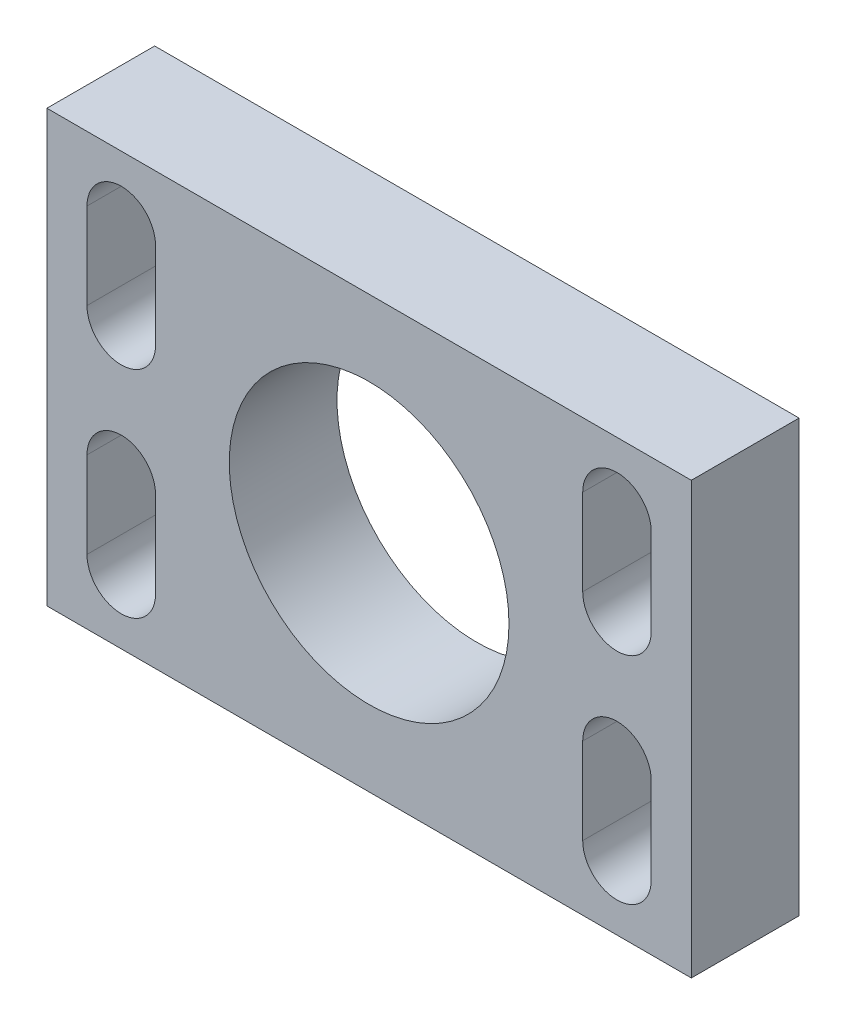
from build123d import *

# Parameters (mm, degrees)
SKETCH1_W                    = 29.9
SKETCH1_H                    = 5
BOSS_EXTRUDE1_DEPTH          = 20
SM05_THREADED_HOLE_REACH     = 33.395
F_4_40_CLEARANCE_SLOTS_REACH = 33.395


with BuildPart() as part:
    # Sketch1 → Boss-Extrude1 (new body)
    with BuildSketch(Plane(origin=(0, 0, 0), x_dir=(1, 0, 0), z_dir=(0, 1, 0))):
        with Locations((8.728625954, 0.935114504)):
            Rectangle(SKETCH1_W, SKETCH1_H)
    extrude(amount=BOSS_EXTRUDE1_DEPTH)

    # Sketch2 → SM05 threaded hole (cut, up to next)
    with BuildSketch(Plane.XY.offset(1.564885496), mode=Mode.PRIVATE) as sm05_threaded_hole_sk1:
        with BuildLine():
            ThreePointArc((15.218325954, 10), (13.317536832, 14.588910878), (8.728625954, 16.4897))
            Line((8.728625954, 16.4897), (8.728625954, 10))
            Line((8.728625954, 10), (15.218325954, 10))
        make_face()
    sm05_threaded_hole_tool1 = extrude(sm05_threaded_hole_sk1.sketch, amount=-SM05_THREADED_HOLE_REACH, mode=Mode.PRIVATE) & part.part
    # Sketch2 → SM05 threaded hole (cut, up to next)
    with BuildSketch(Plane.XY.offset(1.564885496), mode=Mode.PRIVATE) as sm05_threaded_hole_sk2:
        with BuildLine():
            Line((8.728625954, 10), (8.728625954, 16.4897))
            ThreePointArc((8.728625954, 16.4897), (4.139715076, 14.588910878), (2.238925954, 10))
            Line((2.238925954, 10), (8.728625954, 10))
        make_face()
    sm05_threaded_hole_tool2 = extrude(sm05_threaded_hole_sk2.sketch, amount=-SM05_THREADED_HOLE_REACH, mode=Mode.PRIVATE) & part.part
    # Sketch2 → SM05 threaded hole (cut, up to next)
    with BuildSketch(Plane.XY.offset(1.564885496), mode=Mode.PRIVATE) as sm05_threaded_hole_sk3:
        with BuildLine():
            Line((15.218325954, 10), (8.728625954, 10))
            Line((8.728625954, 10), (8.728625954, 3.5103))
            ThreePointArc((8.728625954, 3.5103), (13.317536832, 5.411089122), (15.218325954, 10))
        make_face()
    sm05_threaded_hole_tool3 = extrude(sm05_threaded_hole_sk3.sketch, amount=-SM05_THREADED_HOLE_REACH, mode=Mode.PRIVATE) & part.part
    # Sketch2 → SM05 threaded hole (cut, up to next)
    with BuildSketch(Plane.XY.offset(1.564885496), mode=Mode.PRIVATE) as sm05_threaded_hole_sk4:
        with BuildLine():
            Line((8.728625954, 3.5103), (8.728625954, 10))
            Line((8.728625954, 10), (2.238925954, 10))
            ThreePointArc((2.238925954, 10), (4.139715076, 5.411089122), (8.728625954, 3.5103))
        make_face()
    sm05_threaded_hole_tool4 = extrude(sm05_threaded_hole_sk4.sketch, amount=-SM05_THREADED_HOLE_REACH, mode=Mode.PRIVATE) & part.part
    # Sketch2 → SM05 threaded hole (cut, up to next)
    with BuildSketch(Plane.XY.offset(1.564885496), mode=Mode.PRIVATE) as sm05_threaded_hole_sk5:
        with BuildLine():
            ThreePointArc((15.218325954, 10), (13.317536832, 14.588910878), (8.728625954, 16.4897))
            Line((8.728625954, 16.4897), (8.728625954, 10))
            Line((8.728625954, 10), (15.218325954, 10))
        make_face()
    sm05_threaded_hole_tool5 = extrude(sm05_threaded_hole_sk5.sketch, amount=-SM05_THREADED_HOLE_REACH, mode=Mode.PRIVATE) & part.part
    # Sketch2 → SM05 threaded hole (cut, up to next)
    with BuildSketch(Plane.XY.offset(1.564885496), mode=Mode.PRIVATE) as sm05_threaded_hole_sk6:
        with BuildLine():
            Line((8.728625954, 10), (8.728625954, 16.4897))
            ThreePointArc((8.728625954, 16.4897), (4.139715076, 14.588910878), (2.238925954, 10))
            Line((2.238925954, 10), (8.728625954, 10))
        make_face()
    sm05_threaded_hole_tool6 = extrude(sm05_threaded_hole_sk6.sketch, amount=-SM05_THREADED_HOLE_REACH, mode=Mode.PRIVATE) & part.part
    # Sketch2 → SM05 threaded hole (cut, up to next)
    with BuildSketch(Plane.XY.offset(1.564885496), mode=Mode.PRIVATE) as sm05_threaded_hole_sk7:
        with BuildLine():
            Line((15.218325954, 10), (8.728625954, 10))
            Line((8.728625954, 10), (8.728625954, 3.5103))
            ThreePointArc((8.728625954, 3.5103), (13.317536832, 5.411089122), (15.218325954, 10))
        make_face()
    sm05_threaded_hole_tool7 = extrude(sm05_threaded_hole_sk7.sketch, amount=-SM05_THREADED_HOLE_REACH, mode=Mode.PRIVATE) & part.part
    # Sketch2 → SM05 threaded hole (cut, up to next)
    with BuildSketch(Plane.XY.offset(1.564885496), mode=Mode.PRIVATE) as sm05_threaded_hole_sk8:
        with BuildLine():
            Line((8.728625954, 3.5103), (8.728625954, 10))
            Line((8.728625954, 10), (2.238925954, 10))
            ThreePointArc((2.238925954, 10), (4.139715076, 5.411089122), (8.728625954, 3.5103))
        make_face()
    sm05_threaded_hole_tool8 = extrude(sm05_threaded_hole_sk8.sketch, amount=-SM05_THREADED_HOLE_REACH, mode=Mode.PRIVATE) & part.part
    # Sketch2 → SM05 threaded hole (cut, up to next)
    with BuildSketch(Plane.XY.offset(1.564885496), mode=Mode.PRIVATE) as sm05_threaded_hole_sk9:
        with BuildLine():
            ThreePointArc((15.218325954, 10), (13.317536832, 14.588910878), (8.728625954, 16.4897))
            Line((8.728625954, 16.4897), (8.728625954, 10))
            Line((8.728625954, 10), (15.218325954, 10))
        make_face()
    sm05_threaded_hole_tool9 = extrude(sm05_threaded_hole_sk9.sketch, amount=-SM05_THREADED_HOLE_REACH, mode=Mode.PRIVATE) & part.part
    # Sketch2 → SM05 threaded hole (cut, up to next)
    with BuildSketch(Plane.XY.offset(1.564885496), mode=Mode.PRIVATE) as sm05_threaded_hole_sk10:
        with BuildLine():
            Line((8.728625954, 10), (8.728625954, 16.4897))
            ThreePointArc((8.728625954, 16.4897), (4.139715076, 14.588910878), (2.238925954, 10))
            Line((2.238925954, 10), (8.728625954, 10))
        make_face()
    sm05_threaded_hole_tool10 = extrude(sm05_threaded_hole_sk10.sketch, amount=-SM05_THREADED_HOLE_REACH, mode=Mode.PRIVATE) & part.part
    # Sketch2 → SM05 threaded hole (cut, up to next)
    with BuildSketch(Plane.XY.offset(1.564885496), mode=Mode.PRIVATE) as sm05_threaded_hole_sk11:
        with BuildLine():
            Line((15.218325954, 10), (8.728625954, 10))
            Line((8.728625954, 10), (8.728625954, 3.5103))
            ThreePointArc((8.728625954, 3.5103), (13.317536832, 5.411089122), (15.218325954, 10))
        make_face()
    sm05_threaded_hole_tool11 = extrude(sm05_threaded_hole_sk11.sketch, amount=-SM05_THREADED_HOLE_REACH, mode=Mode.PRIVATE) & part.part
    # Sketch2 → SM05 threaded hole (cut, up to next)
    with BuildSketch(Plane.XY.offset(1.564885496), mode=Mode.PRIVATE) as sm05_threaded_hole_sk12:
        with BuildLine():
            Line((8.728625954, 3.5103), (8.728625954, 10))
            Line((8.728625954, 10), (2.238925954, 10))
            ThreePointArc((2.238925954, 10), (4.139715076, 5.411089122), (8.728625954, 3.5103))
        make_face()
    sm05_threaded_hole_tool12 = extrude(sm05_threaded_hole_sk12.sketch, amount=-SM05_THREADED_HOLE_REACH, mode=Mode.PRIVATE) & part.part
    # Sketch2 → SM05 threaded hole (cut, up to next)
    with BuildSketch(Plane.XY.offset(1.564885496), mode=Mode.PRIVATE) as sm05_threaded_hole_sk13:
        with BuildLine():
            ThreePointArc((15.218325954, 10), (13.317536832, 14.588910878), (8.728625954, 16.4897))
            Line((8.728625954, 16.4897), (8.728625954, 10))
            Line((8.728625954, 10), (15.218325954, 10))
        make_face()
    sm05_threaded_hole_tool13 = extrude(sm05_threaded_hole_sk13.sketch, amount=-SM05_THREADED_HOLE_REACH, mode=Mode.PRIVATE) & part.part
    # Sketch2 → SM05 threaded hole (cut, up to next)
    with BuildSketch(Plane.XY.offset(1.564885496), mode=Mode.PRIVATE) as sm05_threaded_hole_sk14:
        with BuildLine():
            Line((8.728625954, 10), (8.728625954, 16.4897))
            ThreePointArc((8.728625954, 16.4897), (4.139715076, 14.588910878), (2.238925954, 10))
            Line((2.238925954, 10), (8.728625954, 10))
        make_face()
    sm05_threaded_hole_tool14 = extrude(sm05_threaded_hole_sk14.sketch, amount=-SM05_THREADED_HOLE_REACH, mode=Mode.PRIVATE) & part.part
    # Sketch2 → SM05 threaded hole (cut, up to next)
    with BuildSketch(Plane.XY.offset(1.564885496), mode=Mode.PRIVATE) as sm05_threaded_hole_sk15:
        with BuildLine():
            Line((15.218325954, 10), (8.728625954, 10))
            Line((8.728625954, 10), (8.728625954, 3.5103))
            ThreePointArc((8.728625954, 3.5103), (13.317536832, 5.411089122), (15.218325954, 10))
        make_face()
    sm05_threaded_hole_tool15 = extrude(sm05_threaded_hole_sk15.sketch, amount=-SM05_THREADED_HOLE_REACH, mode=Mode.PRIVATE) & part.part
    # Sketch2 → SM05 threaded hole (cut, up to next)
    with BuildSketch(Plane.XY.offset(1.564885496), mode=Mode.PRIVATE) as sm05_threaded_hole_sk16:
        with BuildLine():
            Line((8.728625954, 3.5103), (8.728625954, 10))
            Line((8.728625954, 10), (2.238925954, 10))
            ThreePointArc((2.238925954, 10), (4.139715076, 5.411089122), (8.728625954, 3.5103))
        make_face()
    sm05_threaded_hole_tool16 = extrude(sm05_threaded_hole_sk16.sketch, amount=-SM05_THREADED_HOLE_REACH, mode=Mode.PRIVATE) & part.part
    add(sm05_threaded_hole_tool1.solids().sort_by_distance((11.48294, 12.754314, 1.564885))[0], mode=Mode.SUBTRACT)
    add(sm05_threaded_hole_tool2.solids().sort_by_distance((5.974312, 12.754314, 1.564885))[0], mode=Mode.SUBTRACT)
    add(sm05_threaded_hole_tool3.solids().sort_by_distance((11.48294, 7.245686, 1.564885))[0], mode=Mode.SUBTRACT)
    add(sm05_threaded_hole_tool4.solids().sort_by_distance((5.974312, 7.245686, 1.564885))[0], mode=Mode.SUBTRACT)
    add(sm05_threaded_hole_tool5.solids().sort_by_distance((11.48294, 12.754314, 1.564885))[0], mode=Mode.SUBTRACT)
    add(sm05_threaded_hole_tool6.solids().sort_by_distance((5.974312, 12.754314, 1.564885))[0], mode=Mode.SUBTRACT)
    add(sm05_threaded_hole_tool7.solids().sort_by_distance((11.48294, 7.245686, 1.564885))[0], mode=Mode.SUBTRACT)
    add(sm05_threaded_hole_tool8.solids().sort_by_distance((5.974312, 7.245686, 1.564885))[0], mode=Mode.SUBTRACT)
    add(sm05_threaded_hole_tool9.solids().sort_by_distance((11.48294, 12.754314, 1.564885))[0], mode=Mode.SUBTRACT)
    add(sm05_threaded_hole_tool10.solids().sort_by_distance((5.974312, 12.754314, 1.564885))[0], mode=Mode.SUBTRACT)
    add(sm05_threaded_hole_tool11.solids().sort_by_distance((11.48294, 7.245686, 1.564885))[0], mode=Mode.SUBTRACT)
    add(sm05_threaded_hole_tool12.solids().sort_by_distance((5.974312, 7.245686, 1.564885))[0], mode=Mode.SUBTRACT)
    add(sm05_threaded_hole_tool13.solids().sort_by_distance((11.48294, 12.754314, 1.564885))[0], mode=Mode.SUBTRACT)
    add(sm05_threaded_hole_tool14.solids().sort_by_distance((5.974312, 12.754314, 1.564885))[0], mode=Mode.SUBTRACT)
    add(sm05_threaded_hole_tool15.solids().sort_by_distance((11.48294, 7.245686, 1.564885))[0], mode=Mode.SUBTRACT)
    add(sm05_threaded_hole_tool16.solids().sort_by_distance((5.974312, 7.245686, 1.564885))[0], mode=Mode.SUBTRACT)

    # Sketch2_3 → 4-40 clearance slots (cut, up to next)
    with BuildSketch(Plane.XY.offset(1.564885496), mode=Mode.PRIVATE) as f_4_40_clearance_slots_sk1:
        with BuildLine():
            Line((-1.181374046, 13), (-1.181374046, 17))
            ThreePointArc((-1.181374046, 17), (-2.771374046, 18.59), (-4.361374046, 17))
            Line((-4.361374046, 17), (-4.361374046, 13))
            ThreePointArc((-4.361374046, 13), (-2.771374046, 11.41), (-1.181374046, 13))
        make_face()
    f_4_40_clearance_slots_tool1 = extrude(f_4_40_clearance_slots_sk1.sketch, amount=-F_4_40_CLEARANCE_SLOTS_REACH, mode=Mode.PRIVATE) & part.part
    # Sketch2_3 → 4-40 clearance slots (cut, up to next)
    with BuildSketch(Plane.XY.offset(1.564885496), mode=Mode.PRIVATE) as f_4_40_clearance_slots_sk2:
        with BuildLine():
            ThreePointArc((-1.181374046, 3), (-2.771374046, 1.41), (-4.361374046, 3))
            Line((-4.361374046, 3), (-4.361374046, 7))
            ThreePointArc((-4.361374046, 7), (-2.771374046, 8.59), (-1.181374046, 7))
            Line((-1.181374046, 7), (-1.181374046, 3))
        make_face()
    f_4_40_clearance_slots_tool2 = extrude(f_4_40_clearance_slots_sk2.sketch, amount=-F_4_40_CLEARANCE_SLOTS_REACH, mode=Mode.PRIVATE) & part.part
    # Sketch2_3 → 4-40 clearance slots (cut, up to next)
    with BuildSketch(Plane.XY.offset(1.564885496), mode=Mode.PRIVATE) as f_4_40_clearance_slots_sk3:
        with BuildLine():
            Line((18.638625954, 7), (18.638625954, 3))
            ThreePointArc((18.638625954, 3), (20.228625954, 1.41), (21.818625954, 3))
            Line((21.818625954, 3), (21.818625954, 7))
            ThreePointArc((21.818625954, 7), (20.228625954, 8.59), (18.638625954, 7))
        make_face()
    f_4_40_clearance_slots_tool3 = extrude(f_4_40_clearance_slots_sk3.sketch, amount=-F_4_40_CLEARANCE_SLOTS_REACH, mode=Mode.PRIVATE) & part.part
    # Sketch2_3 → 4-40 clearance slots (cut, up to next)
    with BuildSketch(Plane.XY.offset(1.564885496), mode=Mode.PRIVATE) as f_4_40_clearance_slots_sk4:
        with BuildLine():
            ThreePointArc((18.638625954, 17), (20.228625954, 18.59), (21.818625954, 17))
            Line((21.818625954, 17), (21.818625954, 13))
            ThreePointArc((21.818625954, 13), (20.228625954, 11.41), (18.638625954, 13))
            Line((18.638625954, 13), (18.638625954, 17))
        make_face()
    f_4_40_clearance_slots_tool4 = extrude(f_4_40_clearance_slots_sk4.sketch, amount=-F_4_40_CLEARANCE_SLOTS_REACH, mode=Mode.PRIVATE) & part.part
    add(f_4_40_clearance_slots_tool1.solids().sort_by_distance((-2.771374, 15, 1.564885))[0], mode=Mode.SUBTRACT)
    add(f_4_40_clearance_slots_tool2.solids().sort_by_distance((-2.771374, 5, 1.564885))[0], mode=Mode.SUBTRACT)
    add(f_4_40_clearance_slots_tool3.solids().sort_by_distance((20.228626, 5, 1.564885))[0], mode=Mode.SUBTRACT)
    add(f_4_40_clearance_slots_tool4.solids().sort_by_distance((20.228626, 15, 1.564885))[0], mode=Mode.SUBTRACT)


solid = part.part
